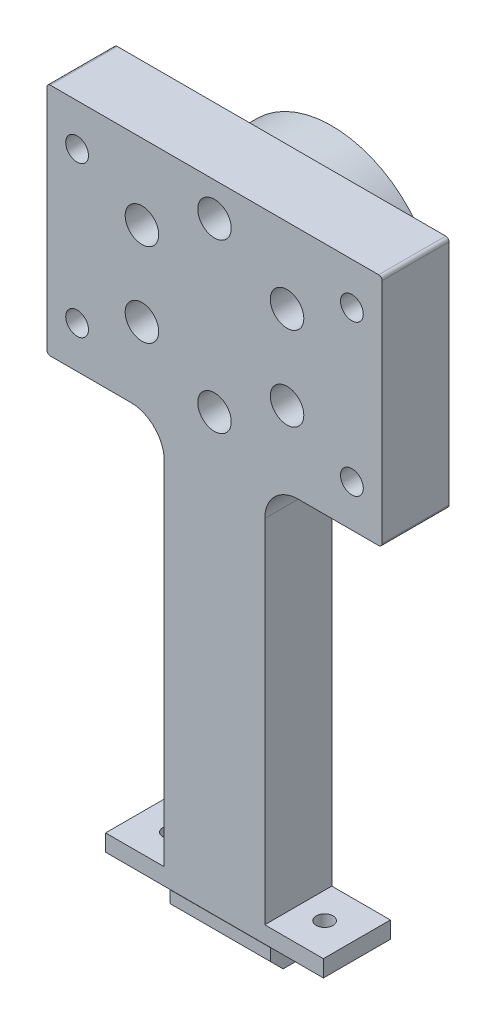
from build123d import *

# Parameters (mm, degrees)
ESTRUSIONE_ESTRUSIONE2_DEPTH      = 1
ESTRUSIONE_ESTRUSIONE2_2_DEPTH    = 1
ESTRUSIONE_ESTRUSIONE3_DEPTH      = 15
SCHIZZO4_W                        = 100
SCHIZZO4_H                        = 70
SCHIZZO4_R                        = 3.4
ESTRUSIONE_ESTRUSIONE4_DEPTH      = 20
SCHIZZO5_R                        = 2.5
TAGLIO_ESTRUSIONE2_DEPTH          = 36
SCHIZZO6_R                        = 5
TAGLIO_ESTRUSIONE3_DEPTH          = 10
SCHIZZO7_R                        = 6
TAGLIO_ESTRUSIONE4_DEPTH          = 8
RACCORDO1_R                       = 1
RACCORDO2_R                       = 1
ESTRUSIONE_ESTRUSIONE5_DEPTH      = 20
RACCORDO3_R                       = 10
ESTRUSIONE_ESTRUSIONE6_DEPTH      = 30
SCHIZZO11_W                       = 20
SCHIZZO11_H                       = 5
ESTRUSIONE_ESTRUSIONE7_DEPTH      = 17.5
ESTRUSIONE_ESTRUSIONE7_DEPTH_BACK = 47.5
TAGLIO_ESTRUSIONE5_REACH          = 192
SCHIZZO13_R                       = 2.5


with BuildPart() as part:
    # Schizzo1 → Estrusione-Estrusione2 (new body)
    with BuildSketch(Plane.XY):
        with BuildLine():
            ThreePointArc((-1482, 0), (-1485, 3), (-1488, 0))
            ThreePointArc((-1488, 0), (-1485, -3), (-1482, 0))
        make_face()
    extrude(amount=-ESTRUSIONE_ESTRUSIONE2_DEPTH)



with BuildPart() as body_2:
    # Schizzo1 → Estrusione-Estrusione2 2 (new body)
    with BuildSketch(Plane.XY):
        with BuildLine():
            ThreePointArc((-1475.75, 0), (-1460, -15.75), (-1444.25, 0))
            ThreePointArc((-1444.25, 0), (-1460, 15.75), (-1475.75, 0))
        make_face()
    extrude(amount=-ESTRUSIONE_ESTRUSIONE2_2_DEPTH)


with BuildPart() as part_1:
    add(part.part)

    add(body_2.part)  # Estrusione-Estrusione3 merges body 2
    # Schizzo2 → Estrusione-Estrusione3 (add)
    with BuildSketch(Plane.XY):
        with BuildLine():
            ThreePointArc((-1491.5, 0), (-1460, -31.5), (-1428.5, 0))
            ThreePointArc((-1428.5, 0), (-1460, 31.5), (-1491.5, 0))
        make_face()
        with BuildLine():
            ThreePointArc((-1479.150635095, -12.5), (-1481.650635095, -10), (-1484.150635095, -12.5))
            ThreePointArc((-1484.150635095, -12.5), (-1481.650635095, -15), (-1479.150635095, -12.5))
        make_face(mode=Mode.SUBTRACT)
        with BuildLine():
            ThreePointArc((-1457.5, -25), (-1460, -22.5), (-1462.5, -25))
            ThreePointArc((-1462.5, -25), (-1460, -27.5), (-1457.5, -25))
        make_face(mode=Mode.SUBTRACT)
        with BuildLine():
            ThreePointArc((-1435.849364905, -12.5), (-1438.349364905, -10), (-1440.849364905, -12.5))
            ThreePointArc((-1440.849364905, -12.5), (-1438.349364905, -15), (-1435.849364905, -12.5))
        make_face(mode=Mode.SUBTRACT)
        with BuildLine():
            ThreePointArc((-1435.849364905, 12.5), (-1438.349364905, 15), (-1440.849364905, 12.5))
            ThreePointArc((-1440.849364905, 12.5), (-1438.349364905, 10), (-1435.849364905, 12.5))
        make_face(mode=Mode.SUBTRACT)
        with BuildLine():
            ThreePointArc((-1462.5, 25), (-1460, 22.5), (-1457.5, 25))
            ThreePointArc((-1457.5, 25), (-1460, 27.5), (-1462.5, 25))
        make_face(mode=Mode.SUBTRACT)
        with BuildLine():
            ThreePointArc((-1479.150635095, 12.5), (-1481.650635095, 15), (-1484.150635095, 12.5))
            ThreePointArc((-1484.150635095, 12.5), (-1481.650635095, 10), (-1479.150635095, 12.5))
        make_face(mode=Mode.SUBTRACT)
    extrude(amount=ESTRUSIONE_ESTRUSIONE3_DEPTH)

    # Schizzo4 → Estrusione-Estrusione4 (add)
    with BuildSketch(Plane.XY.offset(15)):
        with Locations((-1460, 0)):
            Rectangle(SCHIZZO4_W, SCHIZZO4_H)
        with Locations((-1501, 22.5)):
            Circle(SCHIZZO4_R, mode=Mode.SUBTRACT)
        with Locations((-1419, -22.5)):
            Circle(SCHIZZO4_R, mode=Mode.SUBTRACT)
        with Locations((-1419, 22.5)):
            Circle(SCHIZZO4_R, mode=Mode.SUBTRACT)
        with Locations((-1501, -22.5)):
            Circle(SCHIZZO4_R, mode=Mode.SUBTRACT)
    extrude(amount=ESTRUSIONE_ESTRUSIONE4_DEPTH)

    # Schizzo5 → Taglio-Estrusione2 (cut)
    with BuildSketch(Plane(origin=(0, 0, -1), x_dir=(-1, 0, 0), z_dir=(0, 0, -1))):
        with Locations((1438.349364905, 12.5)):
            Circle(SCHIZZO5_R)
        with Locations((1438.349364905, -12.5)):
            Circle(SCHIZZO5_R)
        with Locations((1460, -25)):
            Circle(SCHIZZO5_R)
        with Locations((1481.650635095, -12.5)):
            Circle(SCHIZZO5_R)
        with Locations((1481.650635095, 12.5)):
            Circle(SCHIZZO5_R)
        with Locations((1460, 25)):
            Circle(SCHIZZO5_R)
    extrude(amount=-TAGLIO_ESTRUSIONE2_DEPTH, mode=Mode.SUBTRACT)

    # Schizzo6 → Taglio-Estrusione3 (cut)
    with BuildSketch(Plane.XY.offset(35)):
        with Locations((-1460, 25)):
            Circle(SCHIZZO6_R)
        with Locations((-1438.349364905, 12.5)):
            Circle(SCHIZZO6_R)
        with Locations((-1438.349364905, -12.5)):
            Circle(SCHIZZO6_R)
        with Locations((-1460, -25)):
            Circle(SCHIZZO6_R)
        with Locations((-1481.650635095, -12.5)):
            Circle(SCHIZZO6_R)
        with Locations((-1481.650635095, 12.5)):
            Circle(SCHIZZO6_R)
    extrude(amount=-TAGLIO_ESTRUSIONE3_DEPTH, mode=Mode.SUBTRACT)

    # Schizzo7 → Taglio-Estrusione4 (cut)
    with BuildSketch(Plane(origin=(0, 0, 15), x_dir=(-1, 0, 0), z_dir=(0, 0, -1))):
        with Locations((1419, 22.5)):
            Circle(SCHIZZO7_R)
        with Locations((1501, -22.5)):
            Circle(SCHIZZO7_R)
        with Locations((1501, 22.5)):
            Circle(SCHIZZO7_R)
        with Locations((1419, -22.5)):
            Circle(SCHIZZO7_R)
    extrude(amount=-TAGLIO_ESTRUSIONE4_DEPTH, mode=Mode.SUBTRACT)

    # Raccordo1
    raccordo1_edges = [part_1.edges().sort_by_distance(p)[0] for p in [
        (-1510, 35, 25),
        (-1510, -35, 25),
        (-1410, -35, 25),
        (-1410, 35, 25),
    ]]
    fillet(raccordo1_edges, radius=RACCORDO1_R)

    # Raccordo2
    raccordo2_edges = [part_1.edges().sort_by_distance(p)[0] for p in [
        (-1491.5, 0, 15),
    ]]
    fillet(raccordo2_edges, radius=RACCORDO2_R)

    # Schizzo8 → Estrusione-Estrusione5 (add)
    with BuildSketch(Plane.XY.offset(35)):
        Polygon((-1460, -35), (-1475, -35), (-1475, -155), (-1465.76, -155), (-1445, -155), (-1445, -35), align=None)
    extrude(amount=-ESTRUSIONE_ESTRUSIONE5_DEPTH)

    # Raccordo3
    raccordo3_edges = [part_1.edges().sort_by_distance(p)[0] for p in [
        (-1445, -35, 25),
        (-1475, -35, 25),
    ]]
    fillet(raccordo3_edges, radius=RACCORDO3_R)

    # Schizzo10 → Estrusione-Estrusione6 (add)
    with BuildSketch(Plane.ZY.offset(1475)):
        Polygon((20.7, -155), (20.7, -156.76), (16.7, -156.76), (16.7, -160.36), (20.483021279, -164.143021279), (29.516978721, -164.143021279), (33.3, -160.36), (33.3, -156.76), (29.3, -156.76), (29.3, -155), align=None)
    extrude(amount=-ESTRUSIONE_ESTRUSIONE6_DEPTH)

    # Schizzo11 → Estrusione-Estrusione7 (add, two sides)
    with BuildSketch(Plane(origin=(-1445, 0, 0), x_dir=(0, 0, -1), z_dir=(1, 0, 0))) as estrusione_estrusione7_sk:
        with Locations((-25, -152.5)):
            Rectangle(SCHIZZO11_W, SCHIZZO11_H)
    extrude(amount=ESTRUSIONE_ESTRUSIONE7_DEPTH)
    extrude(estrusione_estrusione7_sk.sketch, amount=-ESTRUSIONE_ESTRUSIONE7_DEPTH_BACK)

    # Schizzo13 → Taglio-Estrusione5 (cut, up to next)
    with BuildSketch(Plane.XZ.offset(155), mode=Mode.PRIVATE) as taglio_estrusione5_sk1:
        with Locations((-1437.15, 25)):
            Circle(SCHIZZO13_R)
    taglio_estrusione5_tool1 = extrude(taglio_estrusione5_sk1.sketch, amount=-TAGLIO_ESTRUSIONE5_REACH, mode=Mode.PRIVATE) & part_1.part
    add(taglio_estrusione5_tool1.solids().sort_by_distance((-1437.15, -155, 25))[0], mode=Mode.SUBTRACT)
    # Schizzo13 → Taglio-Estrusione5 (cut, up to next)
    with BuildSketch(Plane.XZ.offset(155), mode=Mode.PRIVATE) as taglio_estrusione5_sk2:
        with Locations((-1482.85, 25)):
            Circle(SCHIZZO13_R)
    taglio_estrusione5_tool2 = extrude(taglio_estrusione5_sk2.sketch, amount=-TAGLIO_ESTRUSIONE5_REACH, mode=Mode.PRIVATE) & part_1.part
    add(taglio_estrusione5_tool2.solids().sort_by_distance((-1482.85, -155, 25))[0], mode=Mode.SUBTRACT)


solid = part_1.part
